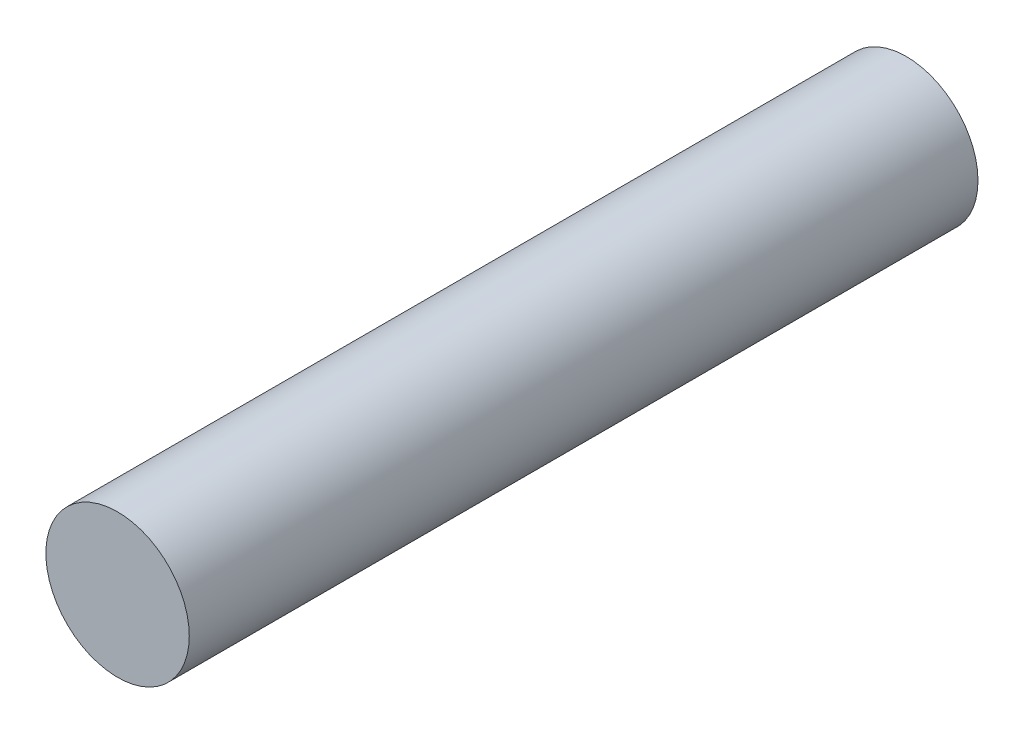
from build123d import *

# Parameters (mm, degrees)
SKETCH1_R           = 3.175
BOSS_EXTRUDE1_DEPTH = 34.925


with BuildPart() as part:
    # Sketch1 → Boss-Extrude1 (new body)
    with BuildSketch(Plane.XY):
        Circle(SKETCH1_R)
    extrude(amount=BOSS_EXTRUDE1_DEPTH)


solid = part.part
